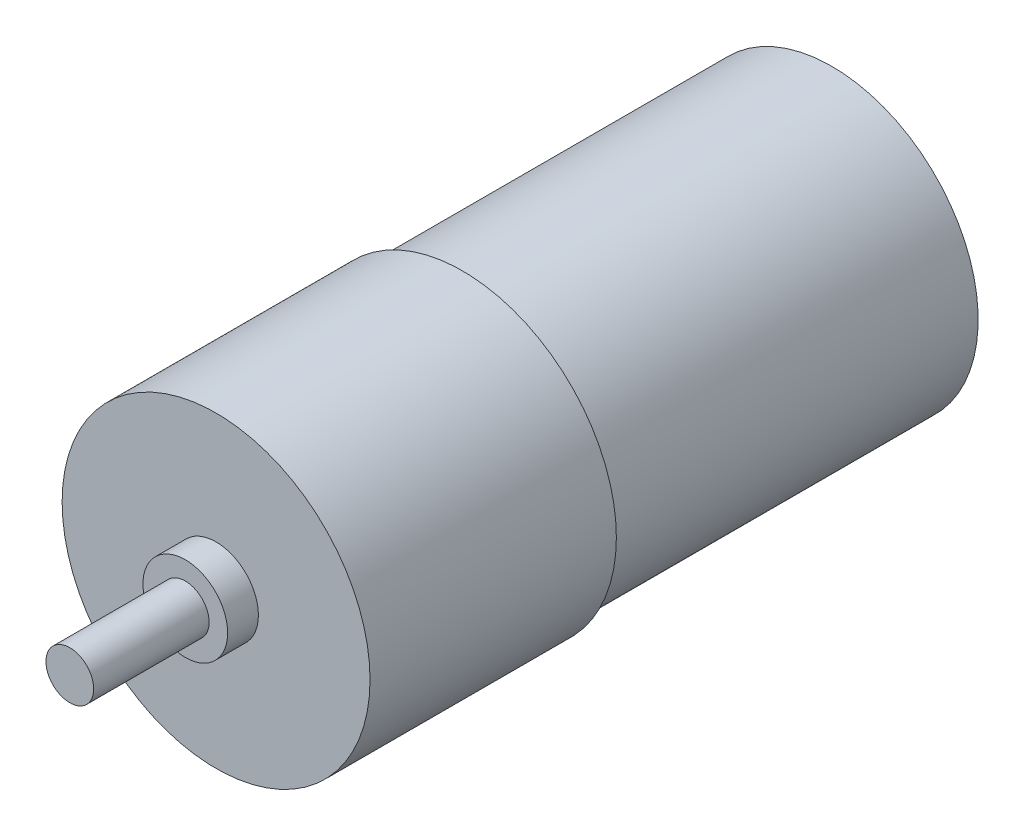
from build123d import *

# Parameters (mm, degrees)
SKETCH1_R           = 12.7
BOSS_EXTRUDE1_DEPTH = 50.8
SKETCH2_R           = 3.4925
BOSS_EXTRUDE2_DEPTH = 2.54
SKETCH3_R           = 1.9685
BOSS_EXTRUDE3_DEPTH = 9.525
SKETCH4_OUTSIDE_W   = 41.88
SKETCH4_OUTSIDE_H   = 41.88
SKETCH4_OUTSIDE_R   = 12.065
CUT_EXTRUDE1_DEPTH  = 30.48


with BuildPart() as part:
    # Sketch1 → Boss-Extrude1 (new body)
    with BuildSketch(Plane.XY):
        Circle(SKETCH1_R)
    extrude(amount=BOSS_EXTRUDE1_DEPTH)

    # Sketch2 → Boss-Extrude2 (add)
    with BuildSketch(Plane.XY.offset(50.8)):
        Circle(SKETCH2_R)
    extrude(amount=BOSS_EXTRUDE2_DEPTH)

    # Sketch3 → Boss-Extrude3 (add)
    with BuildSketch(Plane.XY.offset(53.34)):
        Circle(SKETCH3_R)
    extrude(amount=BOSS_EXTRUDE3_DEPTH)

    # Sketch4 outside → Cut-Extrude1 (cut)
    with BuildSketch(Plane(origin=(0, 0, 0), x_dir=(-1, 0, 0), z_dir=(0, 0, -1))):
        Rectangle(SKETCH4_OUTSIDE_W, SKETCH4_OUTSIDE_H)
        Circle(SKETCH4_OUTSIDE_R, mode=Mode.SUBTRACT)
    extrude(amount=-CUT_EXTRUDE1_DEPTH, mode=Mode.SUBTRACT)


solid = part.part
